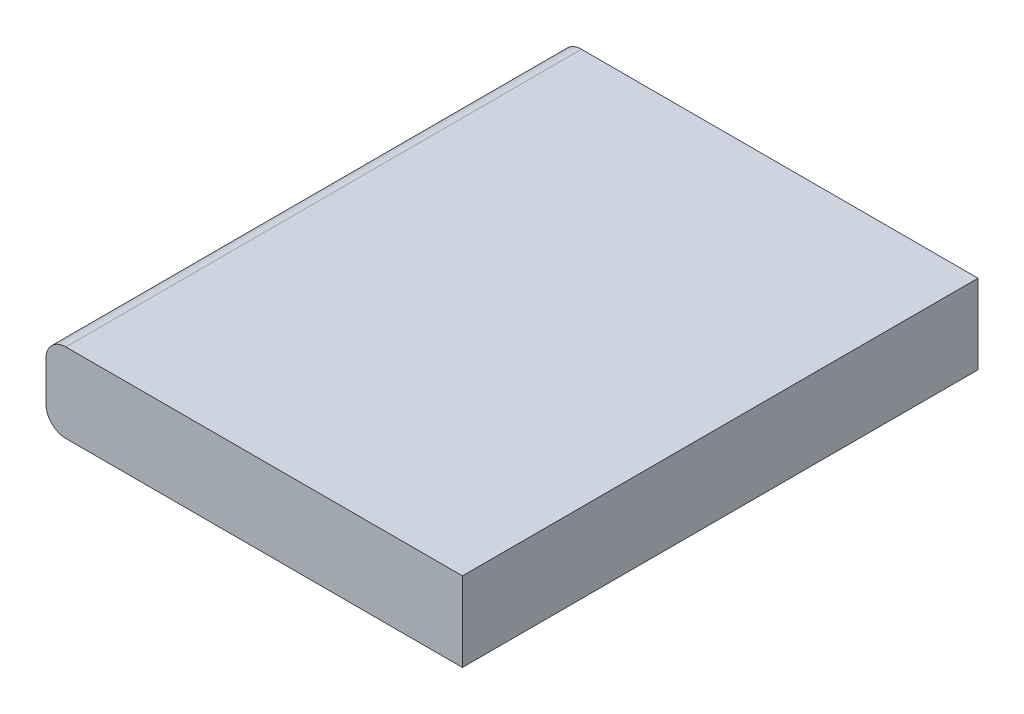
from build123d import *

# Parameters (mm, degrees)
SKETCH_1_W      = 1.05
SKETCH_1_H      = 1.3
EXTRUDE_1_DEPTH = 0.2
FILLET_5_R      = 0.05
FILLET_6_R      = 0.05


with BuildPart() as part:
    # 草图1 → 凸台-拉伸1 (new body)
    with BuildSketch(Plane(origin=(0, 0, 0), x_dir=(1, 0, 0), z_dir=(0, 1, 0))):
        Rectangle(SKETCH_1_W, SKETCH_1_H)
    extrude(amount=EXTRUDE_1_DEPTH)

    # 圆角5
    fillet_5_edges = [part.edges().sort_by_distance(p)[0] for p in [
        (-0.525, 0.2, 0),
    ]]
    fillet(fillet_5_edges, radius=FILLET_5_R)

    # 圆角6
    fillet_6_edges = [part.edges().sort_by_distance(p)[0] for p in [
        (-0.525, 0, 0),
    ]]
    fillet(fillet_6_edges, radius=FILLET_6_R)


solid = part.part
